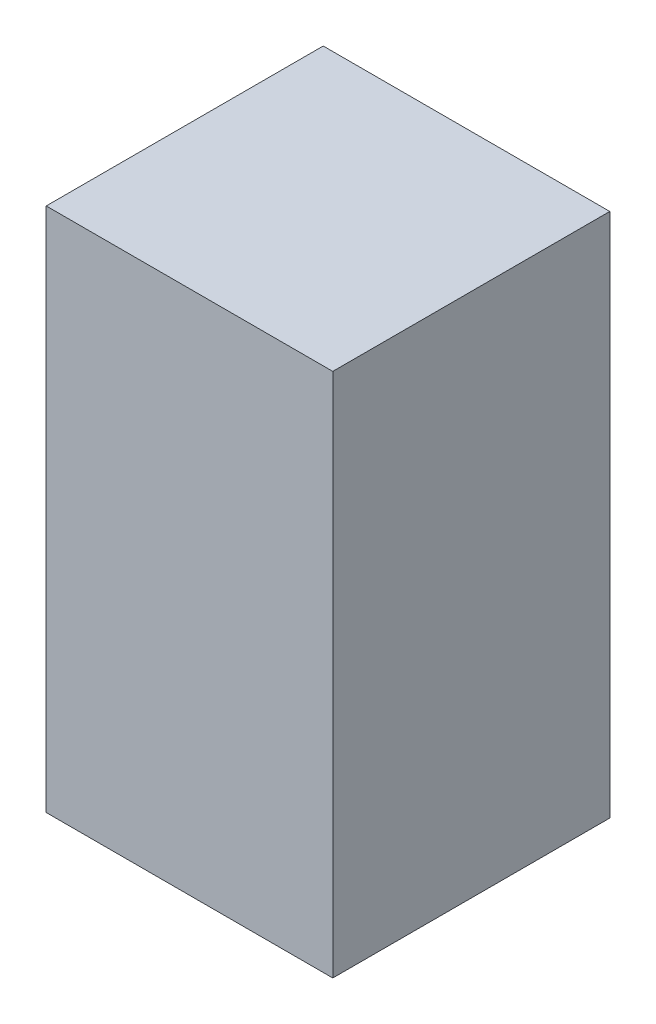
from build123d import *

# Parameters (mm, degrees)
SKETCH1_W           = 1.5
SKETCH1_H           = 1.45
BOSS_EXTRUDE1_DEPTH = 2.75


with BuildPart() as part:
    # Sketch1 → Boss-Extrude1 (new body)
    with BuildSketch(Plane(origin=(0, 0, 0), x_dir=(1, 0, 0), z_dir=(0, 1, 0))):
        with Locations((0.75, 0.725)):
            Rectangle(SKETCH1_W, SKETCH1_H)
    extrude(amount=BOSS_EXTRUDE1_DEPTH)


solid = part.part
